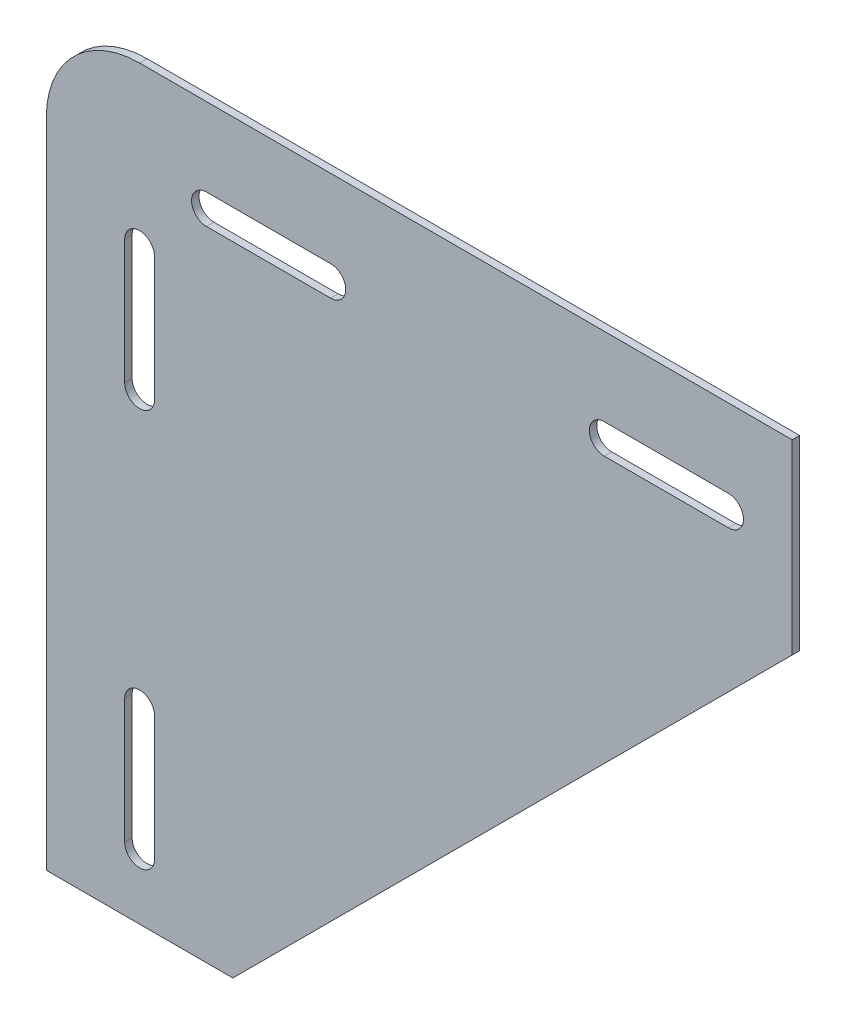
from build123d import *

# Parameters (mm, degrees)
BOSS_EXTRUDE1_DEPTH = 0.762


with BuildPart() as part:
    # Sketch1 → Boss-Extrude1 (new body)
    with BuildSketch(Plane.XY):
        with BuildLine():
            Line((0, -76.2), (0, -9.525))
            ThreePointArc((0, -9.525), (2.789807909, -2.789807909), (9.525, 0))
            Line((9.525, 0), (76.2, 0))
            Line((76.2, 0), (76.2, -19.05))
            Line((76.2, -19.05), (19.05, -76.2))
            Line((19.05, -76.2), (0, -76.2))
        make_face()
        with BuildLine():
            Line((56.9976, -8.001), (69.6976, -8.001))
            ThreePointArc((69.6976, -8.001), (71.2216, -9.525), (69.6976, -11.049))
            Line((69.6976, -11.049), (56.9976, -11.049))
            ThreePointArc((56.9976, -11.049), (55.4736, -9.525), (56.9976, -8.001))
        make_face(mode=Mode.SUBTRACT)
        with BuildLine():
            Line((8.001, -56.9976), (8.001, -69.6976))
            ThreePointArc((8.001, -69.6976), (9.525, -71.2216), (11.049, -69.6976))
            Line((11.049, -69.6976), (11.049, -56.9976))
            ThreePointArc((11.049, -56.9976), (9.525, -55.4736), (8.001, -56.9976))
        make_face(mode=Mode.SUBTRACT)
        with BuildLine():
            Line((29.0576, -11.049), (16.3576, -11.049))
            ThreePointArc((16.3576, -11.049), (14.8336, -9.525), (16.3576, -8.001))
            Line((16.3576, -8.001), (29.0576, -8.001))
            ThreePointArc((29.0576, -8.001), (30.5816, -9.525), (29.0576, -11.049))
        make_face(mode=Mode.SUBTRACT)
        with BuildLine():
            Line((11.049, -29.0576), (11.049, -16.3576))
            ThreePointArc((11.049, -16.3576), (9.525, -14.8336), (8.001, -16.3576))
            Line((8.001, -16.3576), (8.001, -29.0576))
            ThreePointArc((8.001, -29.0576), (9.525, -30.5816), (11.049, -29.0576))
        make_face(mode=Mode.SUBTRACT)
    extrude(amount=BOSS_EXTRUDE1_DEPTH)


solid = part.part
